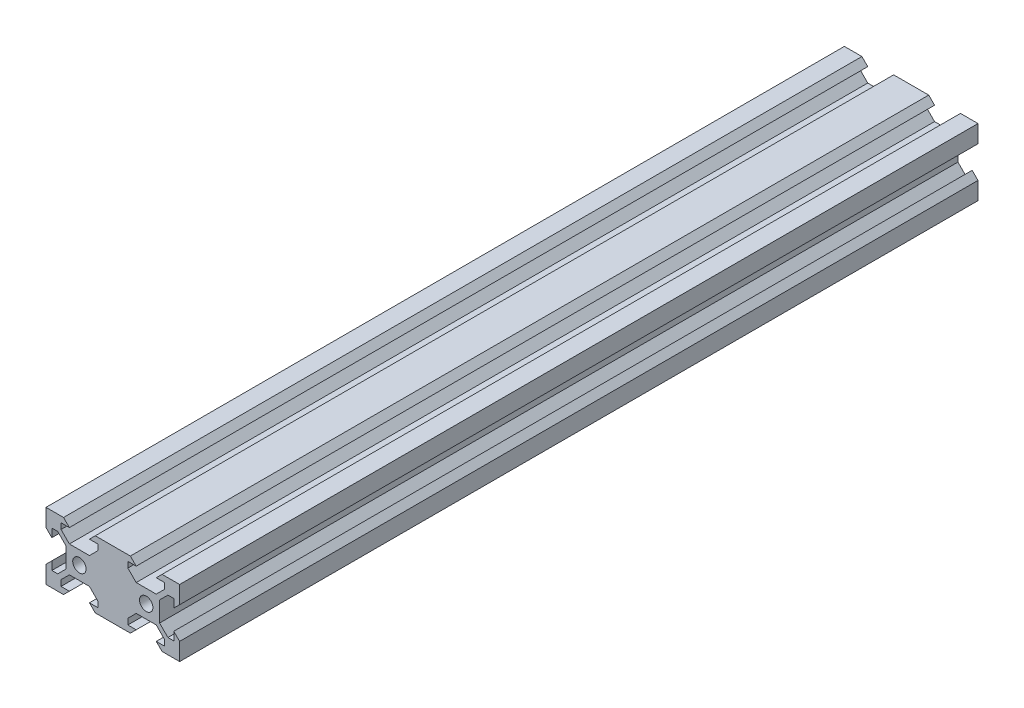
from build123d import *

# Parameters (mm, degrees)
CROQUIS1_R              = 2
SALIENTE_EXTRUIR1_DEPTH = 239


with BuildPart() as part:
    # Croquis1 → Saliente-Extruir1 (new body)
    with BuildSketch(Plane.XY):
        Polygon((-4.75, 10), (-10, 10), (-10, 4.75), (-8.25, 3), (-8.25, 5.5), (-6.5, 5.5), (-4, 3), (-4, -3), (-6.5, -5.5), (-8.25, -5.5), (-8.25, -3), (-10, -4.75), (-10, -10), (-4.75, -10), (-3, -8.25), (-5.5, -8.25), (-5.5, -6.5), (-3, -4), (3, -4), (5.5, -6.5), (5.5, -8.25), (3, -8.25), (4.75, -10), (10, -10), (10, -4.75), (8.25, -3), (8.25, -5.5), (6.5, -5.5), (4, -3), (4, 3), (6.5, 5.5), (8.25, 5.5), (8.25, 3), (10, 4.75), (10, 10), (4.75, 10), (3, 8.25), (5.5, 8.25), (5.5, 6.5), (3, 4), (-3, 4), (-5.5, 6.5), (-5.5, 8.25), (-3, 8.25), align=None)
        Circle(CROQUIS1_R, mode=Mode.SUBTRACT)
        Polygon((15.25, 10), (10, 10), (10, 4.75), (11.75, 3), (11.75, 5.5), (13.5, 5.5), (16, 3), (16, -3), (13.5, -5.5), (11.75, -5.5), (11.75, -3), (10, -4.75), (10, -10), (15.25, -10), (17, -8.25), (14.5, -8.25), (14.5, -6.5), (17, -4), (23, -4), (25.5, -6.5), (25.5, -8.25), (23, -8.25), (24.75, -10), (30, -10), (30, -4.75), (28.25, -3), (28.25, -5.5), (26.5, -5.5), (24, -3), (24, 3), (26.5, 5.5), (28.25, 5.5), (28.25, 3), (30, 4.75), (30, 10), (24.75, 10), (23, 8.25), (25.5, 8.25), (25.5, 6.5), (23, 4), (17, 4), (14.5, 6.5), (14.5, 8.25), (17, 8.25), align=None)
        with Locations((20, 0)):
            Circle(CROQUIS1_R, mode=Mode.SUBTRACT)
        Polygon((11.75, 3), (10, 4.75), (10, -4.75), (11.75, -3), (11.75, -5.5), (13.5, -5.5), (16, -3), (16, 3), (13.5, 5.5), (11.75, 5.5), align=None)
        Polygon((10, -4.75), (10, 4.75), (8.25, 3), (8.25, 5.5), (6.5, 5.5), (4, 3), (4, -3), (6.5, -5.5), (8.25, -5.5), (8.25, -3), align=None)
    extrude(amount=SALIENTE_EXTRUIR1_DEPTH)


solid = part.part
